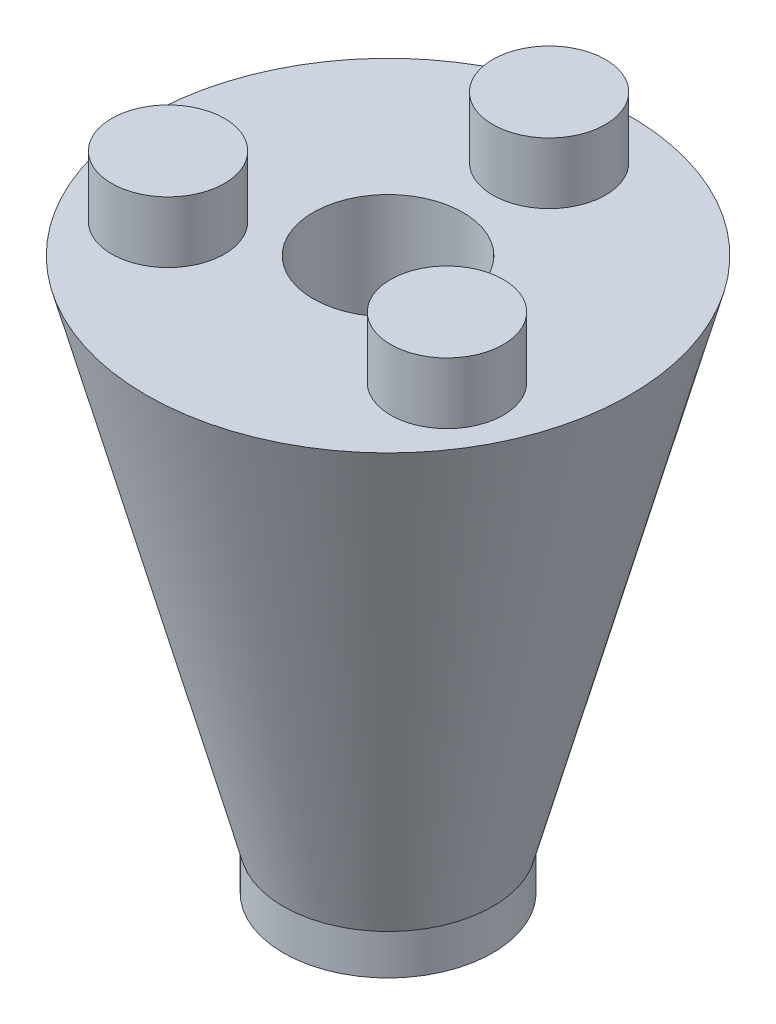
from build123d import *

# Parameters (mm, degrees)
SKETCH1_R            = 6.500000081
ANGLEBODY_DEPTH      = 31.75
ANGLEBODY_DRAFT      = -15
SKETCH2_R            = 4.649999971
SKETCH2_R_2          = 1.93499994
CENTERHOLE_DEPTH     = 39.190389178
F_40TPEGS_DEPTH      = 3.80000002
SKETCH3_R            = 6.500000081
SKETCH3_R_2          = 3.300000004
F_20TINTERFACE_DEPTH = 2.50000008


with BuildPart() as part:
    # Sketch1 → AngleBody (with draft: the straight prism first)
    with BuildSketch(Plane(origin=(0, 0, 0), x_dir=(1, 0, 0), z_dir=(0, 1, 0))):
        Circle(SKETCH1_R)
    extrude(amount=ANGLEBODY_DEPTH)
    # AngleBody: the draft: its side faces are tilted about the plane it starts from
    anglebody_sides = [part.faces().sort_by_distance(p)[0] for p in [
        (-6.500000081, 15.875, 0),
    ]]
    draft(anglebody_sides, Plane(origin=(0, 0, 0), x_dir=(1, 0, 0), z_dir=(0, 1, 0)), ANGLEBODY_DRAFT)

    # Sketch2 → CenterHole (cut, through all)
    with BuildSketch(Plane(origin=(0, 31.75, 0), x_dir=(1, 0, 0), z_dir=(0, 1, 0))):
        with Locations(Location((0, 0, 0), (0, 0, 270))):
            Circle(SKETCH2_R)
        Circle(SKETCH2_R_2, mode=Mode.SUBTRACT)
        Circle(SKETCH2_R_2)
    extrude(amount=-CENTERHOLE_DEPTH, mode=Mode.SUBTRACT)

    # Sketch2_3 → 40tPegs (add)
    with BuildSketch(Plane(origin=(0, 31.75, 0), x_dir=(1, 0, 0), z_dir=(0, 1, 0))):
        with BuildLine():
            ThreePointArc((3.499999985, 10.000000066), (-1.749999993, 13.031088966), (-1.749999992, 6.968911166))
            Line((-1.749999992, 6.968911166), (0, 10.000000066))
            Line((0, 10.000000066), (1.749999992, 6.968911166))
            ThreePointArc((1.749999992, 6.968911166), (3.0310889, 8.250000073), (3.499999985, 10.000000066))
        make_face()
        with BuildLine():
            Line((0, 10.000000066), (-1.749999992, 6.968911166))
            ThreePointArc((-1.749999992, 6.968911166), (0, 6.500000081), (1.749999992, 6.968911166))
            Line((1.749999992, 6.968911166), (0, 10.000000066))
        make_face()
        with BuildLine():
            ThreePointArc((3.499999985, 10.000000066), (-1.749999993, 13.031088966), (-1.749999992, 6.968911166))
            Line((-1.749999992, 6.968911166), (0, 10.000000066))
            Line((0, 10.000000066), (1.749999992, 6.968911166))
            ThreePointArc((1.749999992, 6.968911166), (3.0310889, 8.250000073), (3.499999985, 10.000000066))
        make_face()
        with BuildLine():
            Line((0, 10.000000066), (-1.749999992, 6.968911166))
            ThreePointArc((-1.749999992, 6.968911166), (0, 6.500000081), (1.749999992, 6.968911166))
            Line((1.749999992, 6.968911166), (0, 10.000000066))
        make_face()
        with BuildLine():
            Line((-6.910254103, -1.968911133), (-8.660254095, -5.000000033))
            Line((-8.660254095, -5.000000033), (-5.16025411, -5.000000033))
            ThreePointArc((-5.16025411, -5.000000033), (-5.629165195, -3.25000004), (-6.910254103, -1.968911133))
        make_face()
        with BuildLine():
            Line((-5.16025411, -5.000000033), (-8.660254095, -5.000000033))
            Line((-8.660254095, -5.000000033), (-6.910254103, -1.968911133))
            ThreePointArc((-6.910254103, -1.968911133), (-11.691342995, -6.750000026), (-5.16025411, -5.000000033))
        make_face()
        with BuildLine():
            Line((-6.910254103, -1.968911133), (-8.660254095, -5.000000033))
            Line((-8.660254095, -5.000000033), (-5.16025411, -5.000000033))
            ThreePointArc((-5.16025411, -5.000000033), (-5.629165195, -3.25000004), (-6.910254103, -1.968911133))
        make_face()
        with BuildLine():
            Line((-5.16025411, -5.000000033), (-8.660254095, -5.000000033))
            Line((-8.660254095, -5.000000033), (-6.910254103, -1.968911133))
            ThreePointArc((-6.910254103, -1.968911133), (-11.691342995, -6.750000026), (-5.16025411, -5.000000033))
        make_face()
        with BuildLine():
            ThreePointArc((6.910254103, -1.968911133), (5.629165195, -3.25000004), (5.16025411, -5.000000033))
            Line((5.16025411, -5.000000033), (8.660254095, -5.000000033))
            Line((8.660254095, -5.000000033), (6.910254103, -1.968911133))
        make_face()
        with BuildLine():
            Line((8.660254095, -5.000000033), (5.16025411, -5.000000033))
            ThreePointArc((5.16025411, -5.000000033), (8.660254095, -8.500000018), (12.16025408, -5.000000033))
            ThreePointArc((12.16025408, -5.000000033), (10.410254088, -1.968911133), (6.910254103, -1.968911133))
            Line((6.910254103, -1.968911133), (8.660254095, -5.000000033))
        make_face()
        with BuildLine():
            ThreePointArc((6.910254103, -1.968911133), (5.629165195, -3.25000004), (5.16025411, -5.000000033))
            Line((5.16025411, -5.000000033), (8.660254095, -5.000000033))
            Line((8.660254095, -5.000000033), (6.910254103, -1.968911133))
        make_face()
        with BuildLine():
            Line((8.660254095, -5.000000033), (5.16025411, -5.000000033))
            ThreePointArc((5.16025411, -5.000000033), (8.660254095, -8.500000018), (12.16025408, -5.000000033))
            ThreePointArc((12.16025408, -5.000000033), (10.410254088, -1.968911133), (6.910254103, -1.968911133))
            Line((6.910254103, -1.968911133), (8.660254095, -5.000000033))
        make_face()
    extrude(amount=F_40TPEGS_DEPTH)

    # Sketch3 → 20tInterface (add)
    with BuildSketch(Plane.XZ):
        with Locations(Location((0, 0, 0), (0, 0, 270))):
            Circle(SKETCH3_R)
        with Locations(Location((0, 0, 0), (0, 0, 270))):
            Circle(SKETCH3_R_2, mode=Mode.SUBTRACT)
    extrude(amount=F_20TINTERFACE_DEPTH)


solid = part.part
